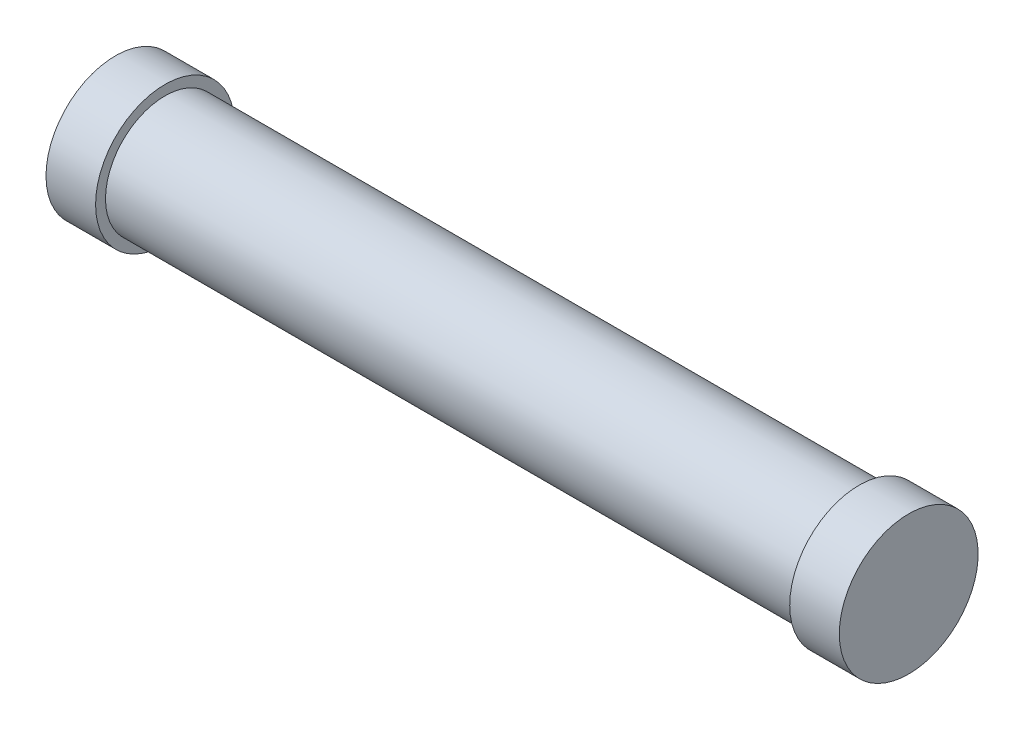
from build123d import *

# Parameters (mm, degrees)
SKETCH1_W           = 70
SKETCH1_H           = 6
SKETCH2_R           = 7
BOSS_EXTRUDE1_DEPTH = 5


with BuildPart() as part:
    # Sketch1 → Revolve1 (revolve)
    with BuildSketch(Plane(origin=(0, 0, 0), x_dir=(1, 0, 0), z_dir=(0, 1, 0))):
        with Locations((0.279538905, 9)):
            Rectangle(SKETCH1_W, SKETCH1_H)
    revolve(axis=Axis((-34.720461095, 0, -6), (1, 0, 0)))

    # Sketch2 → Boss-Extrude1 (add)
    with BuildSketch(Plane.ZY.offset(34.720461095)):
        with Locations((-6, 0)):
            Circle(SKETCH2_R)
    boss_extrude1 = extrude(amount=BOSS_EXTRUDE1_DEPTH)

    # Mirror1: Boss-Extrude1 across plane
    add(boss_extrude1.mirror(Plane(origin=(0.279538905, 0, 0), x_dir=(0, 0, 1), z_dir=(1, 0, 0))))


solid = part.part
